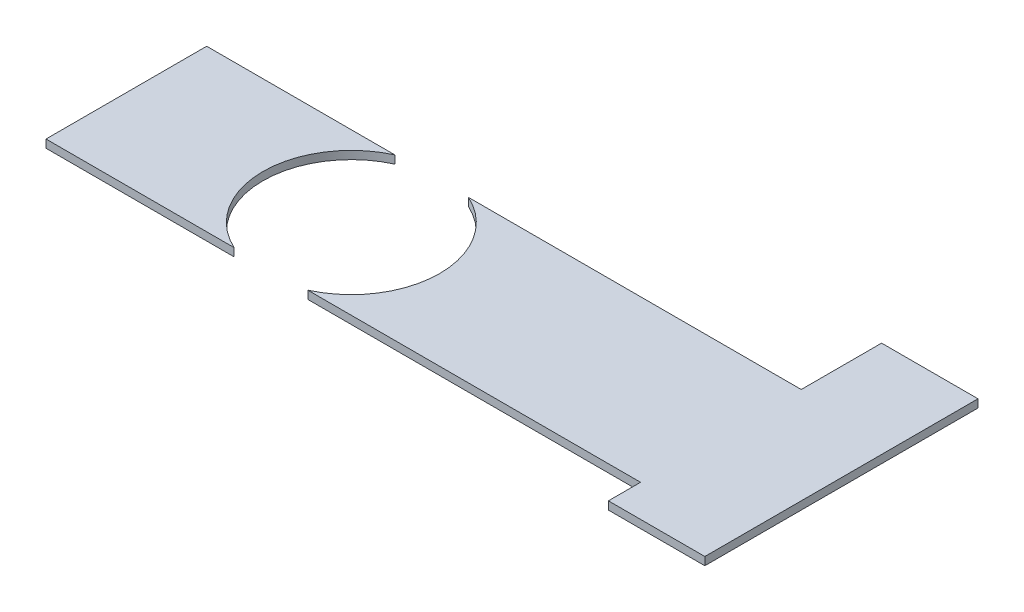
from build123d import *

# Parameters (mm, degrees)
EXTRUDE_1_DEPTH     = 0.5
SKETCH_2_R          = 5.5
CUT_EXTRUDE_1_DEPTH = 1.5


with BuildPart() as part:
    # 草图1 → 凸台-拉伸1 (new body)
    with BuildSketch(Plane(origin=(0, 0, 0), x_dir=(1, 0, 0), z_dir=(0, 1, 0))):
        Polygon((-11.322033898, 5), (25.677966102, 5), (25.677966102, 10), (31.677966102, 10), (31.677966102, -7), (25.677966102, -7), (25.677966102, -5), (-11.322033898, -5), align=None)
    extrude(amount=EXTRUDE_1_DEPTH)

    # 草图2 → 切除-拉伸1 (cut, through all)
    with BuildSketch(Plane.XZ):
        with Locations((2.677966102, 0)):
            Circle(SKETCH_2_R)
    extrude(amount=-CUT_EXTRUDE_1_DEPTH, mode=Mode.SUBTRACT)


solid = part.part
